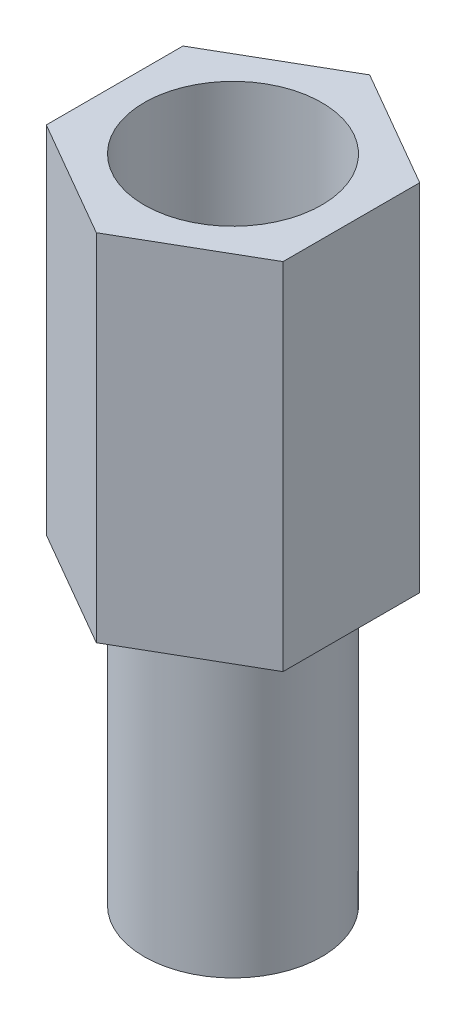
from build123d import *

# Parameters (mm, degrees)
SKETCH_1_R          = 1.5
EXTRUDE_1_DEPTH     = 5
EXTRUDE_2_DEPTH     = 6
SKETCH_3_R          = 1.5
CUT_EXTRUDE_1_DEPTH = 5


with BuildPart() as part:
    # 草图1 → 凸台-拉伸1 (new body)
    with BuildSketch(Plane(origin=(0, 0, 0), x_dir=(1, 0, 0), z_dir=(0, 1, 0))):
        Circle(SKETCH_1_R)
    extrude(amount=EXTRUDE_1_DEPTH)

    # 草图2 → 凸台-拉伸2 (add)
    with BuildSketch(Plane(origin=(0, 5, 0), x_dir=(1, 0, 0), z_dir=(0, 1, 0))):
        Polygon((0, 2.309401077), (-2, 1.154700538), (-2, -1.154700538), (0, -2.309401077), (2, -1.154700538), (2, 1.154700538), align=None)
    extrude(amount=EXTRUDE_2_DEPTH)

    # 草图3 → 切除-拉伸1 (cut)
    with BuildSketch(Plane(origin=(0, 11, 0), x_dir=(1, 0, 0), z_dir=(0, 1, 0))):
        Circle(SKETCH_3_R)
    extrude(amount=-CUT_EXTRUDE_1_DEPTH, mode=Mode.SUBTRACT)


solid = part.part
